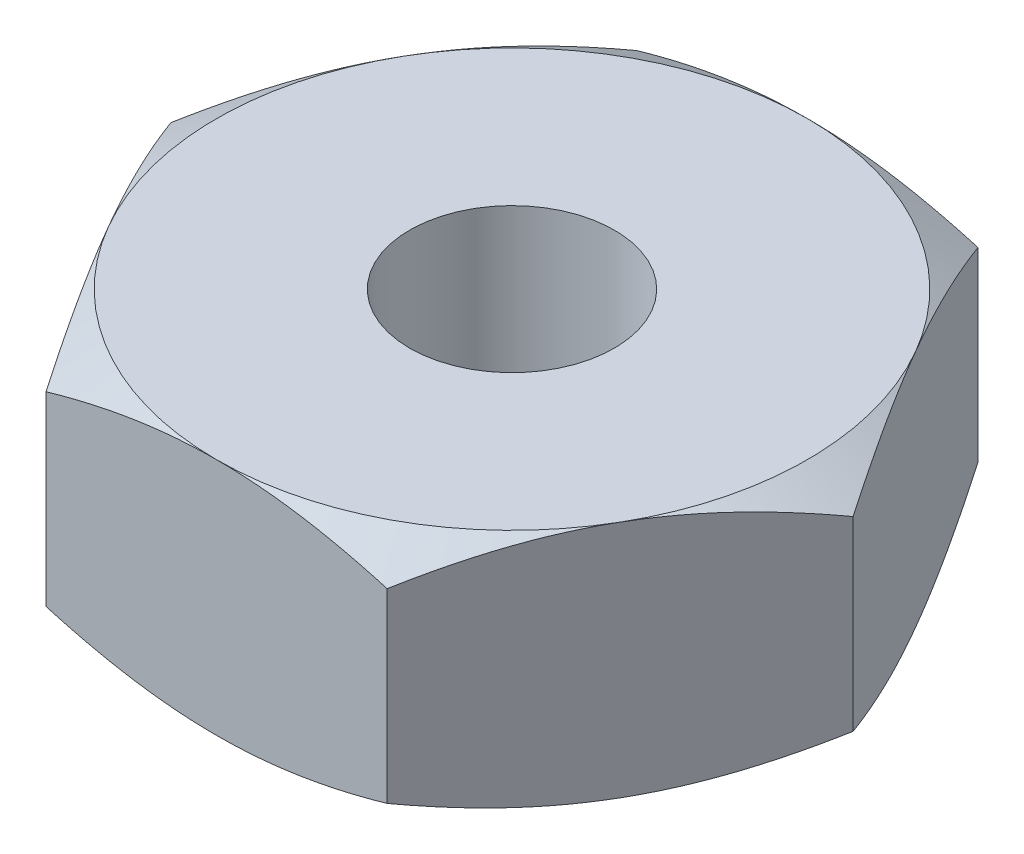
from build123d import *

# Parameters (mm, degrees)
BOSS_EXTRUDE1_DEPTH = 3.5
SKETCH2_OUTSIDE_W   = 51.722
SKETCH2_OUTSIDE_H   = 49.042
SKETCH2_OUTSIDE_R   = 8.660254038
CUT_EXTRUDE1_DEPTH  = 7
CUT_EXTRUDE1_TAPER  = 60
SKETCH3_R           = 3
CUT_EXTRUDE2_DEPTH  = 8


with BuildPart() as part:
    # Sketch1 → Boss-Extrude1 (new body, symmetric)
    with BuildSketch(Plane(origin=(0, 0, 0), x_dir=(1, 0, 0), z_dir=(0, 1, 0))):
        Polygon((-10, 0), (-5, -8.660254038), (5, -8.660254038), (10, 0), (5, 8.660254038), (-5, 8.660254038), align=None)
    extrude(amount=BOSS_EXTRUDE1_DEPTH, both=True)

    # Sketch2 outside → Cut-Extrude1 (cut)
    with BuildSketch(Plane(origin=(0, 3.5, 0), x_dir=(1, 0, 0), z_dir=(0, 1, 0))):
        Rectangle(SKETCH2_OUTSIDE_W, SKETCH2_OUTSIDE_H)
        Circle(SKETCH2_OUTSIDE_R, mode=Mode.SUBTRACT)
    cut_extrude1 = extrude(amount=-CUT_EXTRUDE1_DEPTH, taper=CUT_EXTRUDE1_TAPER, mode=Mode.SUBTRACT)

    # Mirror1: Cut-Extrude1 across plane
    add(cut_extrude1.mirror(Plane.ZX), mode=Mode.SUBTRACT)

    # Sketch3 → Cut-Extrude2 (cut, through all)
    with BuildSketch(Plane(origin=(0, 3.5, 0), x_dir=(1, 0, 0), z_dir=(0, 1, 0))):
        Circle(SKETCH3_R)
    extrude(amount=-CUT_EXTRUDE2_DEPTH, mode=Mode.SUBTRACT)


solid = part.part
